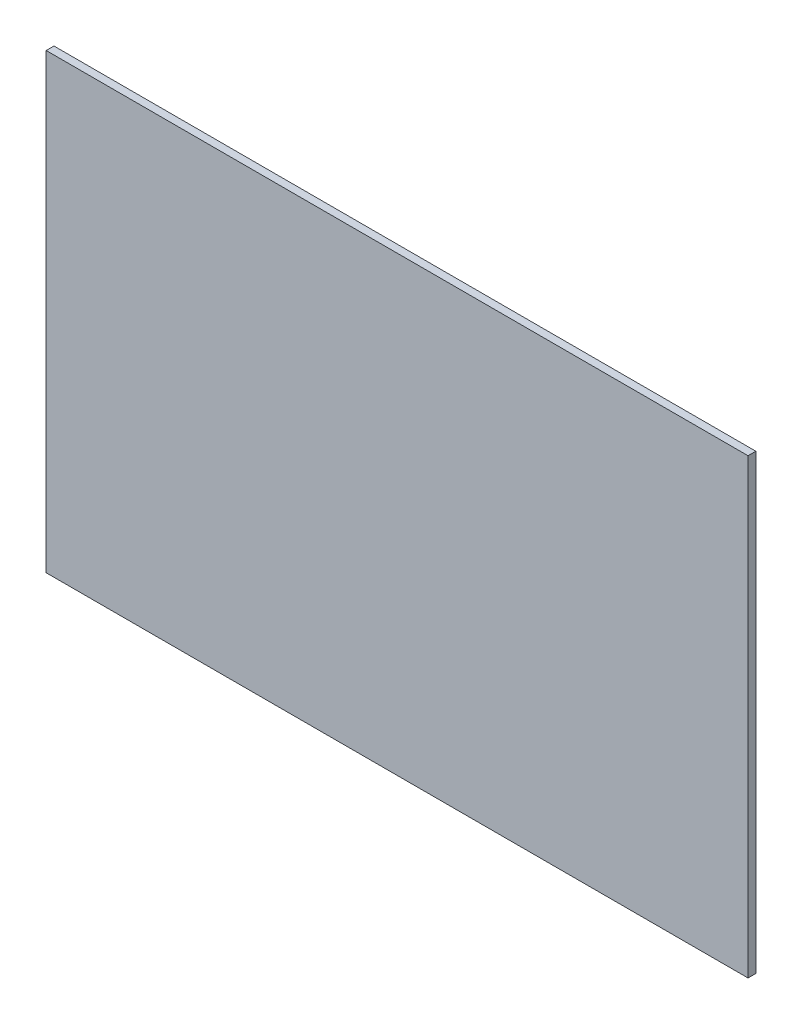
from build123d import *

# Parameters (mm, degrees)
SKETCH1_W           = 571.5
SKETCH1_H           = 368.3
BOSS_EXTRUDE1_DEPTH = 6.35


with BuildPart() as part:
    # Sketch1 → Boss-Extrude1 (new body)
    with BuildSketch(Plane.XY):
        Rectangle(SKETCH1_W, SKETCH1_H)
    extrude(amount=BOSS_EXTRUDE1_DEPTH)


solid = part.part
